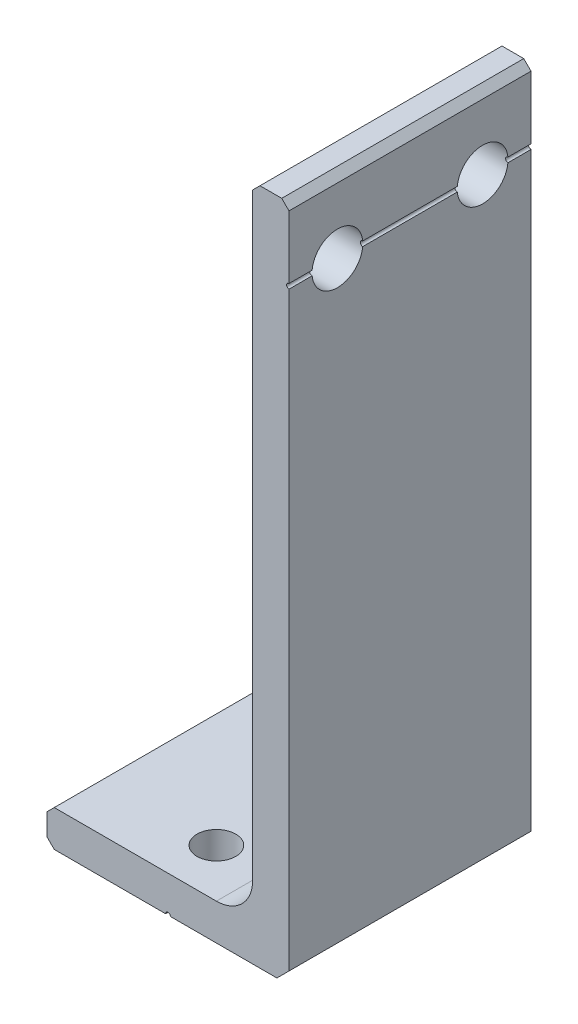
from build123d import *

# Parameters (mm, degrees)
EXTRUDE_1_DEPTH     = 20
FILLET_1_R          = 3
SKETCH_2_R          = 2.1
CUT_EXTRUDE_1_DEPTH = 20
SKETCH_3_R          = 1.6
CUT_EXTRUDE_2_DEPTH = 20
CHAMFER_1_SIZE      = 1
CHAMFER_2_SIZE      = 0.6
SKETCH_4_R          = 0.2
CUT_EXTRUDE_3_DEPTH = 32


with BuildPart() as part:
    # 草图1 → 凸台-拉伸1 (new body)
    with BuildSketch(Plane.XY):
        Polygon((0, 0), (20, 0), (20, 56), (17, 56), (17, 3), (0, 3), align=None)
    extrude(amount=EXTRUDE_1_DEPTH)

    # 圆角1
    fillet_1_edges = [part.edges().sort_by_distance(p)[0] for p in [
        (17, 3, 10),
    ]]
    fillet(fillet_1_edges, radius=FILLET_1_R)

    # 草图2 → 切除-拉伸1 (cut)
    with BuildSketch(Plane.ZY.offset(-17)):
        with Locations((4, 50)):
            Circle(SKETCH_2_R)
        with Locations((16, 50)):
            Circle(SKETCH_2_R)
    extrude(amount=-CUT_EXTRUDE_1_DEPTH, mode=Mode.SUBTRACT)

    # 草图3 → 切除-拉伸2 (cut)
    with BuildSketch(Plane(origin=(0, 3, 0), x_dir=(1, 0, 0), z_dir=(0, 1, 0))):
        with Locations((10, -4)):
            Circle(SKETCH_3_R)
        with Locations((10, -16)):
            Circle(SKETCH_3_R)
    extrude(amount=-CUT_EXTRUDE_2_DEPTH, mode=Mode.SUBTRACT)

    # 倒角1
    chamfer_1_edges = [part.edges().sort_by_distance(p)[0] for p in [
        (20, 0, 10),
    ]]
    chamfer(chamfer_1_edges, length=CHAMFER_1_SIZE)

    # 倒角2
    chamfer_2_edges = [part.edges().sort_by_distance(p)[0] for p in [
        (0, 3, 10),
        (17, 56, 10),
        (20, 56, 10),
        (0, 0, 10),
    ]]
    chamfer(chamfer_2_edges, length=CHAMFER_2_SIZE)

    # 草图4 → 切除-拉伸3 (cut)
    with BuildSketch(Plane.XY.offset(20)):
        with Locations((10, 0)):
            Circle(SKETCH_4_R)
        with Locations((20, 50)):
            Circle(SKETCH_4_R)
    extrude(amount=-CUT_EXTRUDE_3_DEPTH, mode=Mode.SUBTRACT)


solid = part.part
